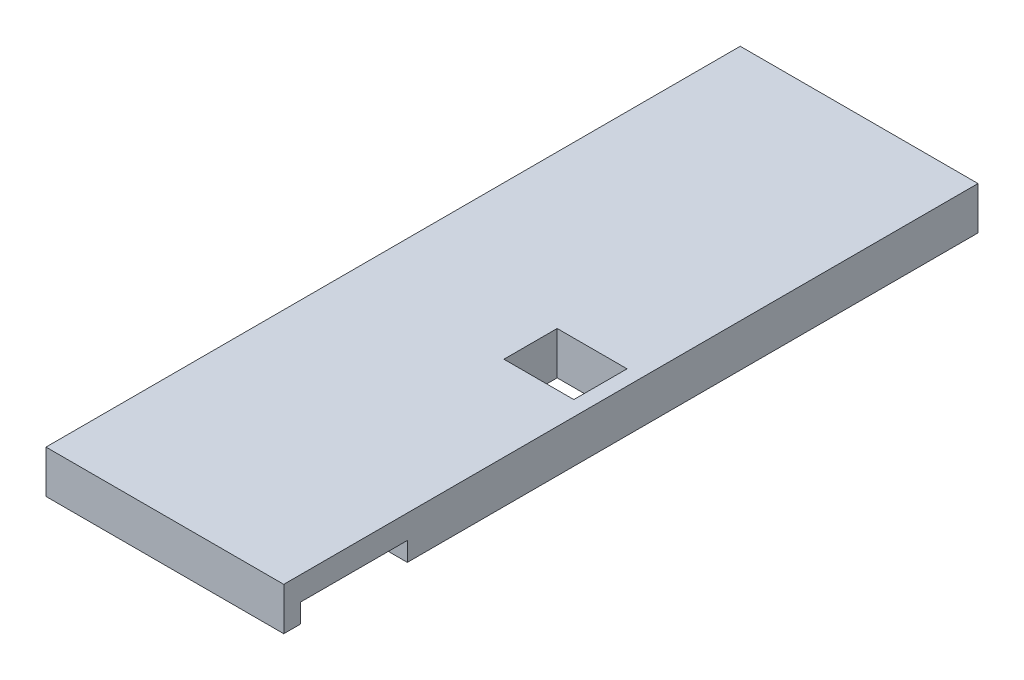
from build123d import *

# Parameters (mm, degrees)
SKETCH1_W           = 100
SKETCH1_H           = 292
BOSS_EXTRUDE1_DEPTH = 9
SKETCH2_W           = 29.4
SKETCH2_H           = 22.4
CUT_EXTRUDE1_DEPTH  = 19
SKETCH3_W           = 13.5
SKETCH3_H           = 45
CUT_EXTRUDE2_DEPTH  = 8


with BuildPart() as part:
    # Sketch1 → Boss-Extrude1 (new body, symmetric)
    with BuildSketch(Plane(origin=(0, 0, 0), x_dir=(1, 0, 0), z_dir=(0, 1, 0))):
        Rectangle(SKETCH1_W, SKETCH1_H)
    extrude(amount=BOSS_EXTRUDE1_DEPTH, both=True)

    # Sketch2 → Cut-Extrude1 (cut, through all)
    with BuildSketch(Plane.XZ.offset(9)):
        with Locations((29, 6.5)):
            Rectangle(SKETCH2_W, SKETCH2_H)
    extrude(amount=-CUT_EXTRUDE1_DEPTH, mode=Mode.SUBTRACT)

    # Sketch3 → Cut-Extrude2 (cut)
    with BuildSketch(Plane.XZ.offset(9)):
        with Locations((43.25, 116.521105827)):
            Rectangle(SKETCH3_W, SKETCH3_H)
    extrude(amount=-CUT_EXTRUDE2_DEPTH, mode=Mode.SUBTRACT)


solid = part.part
